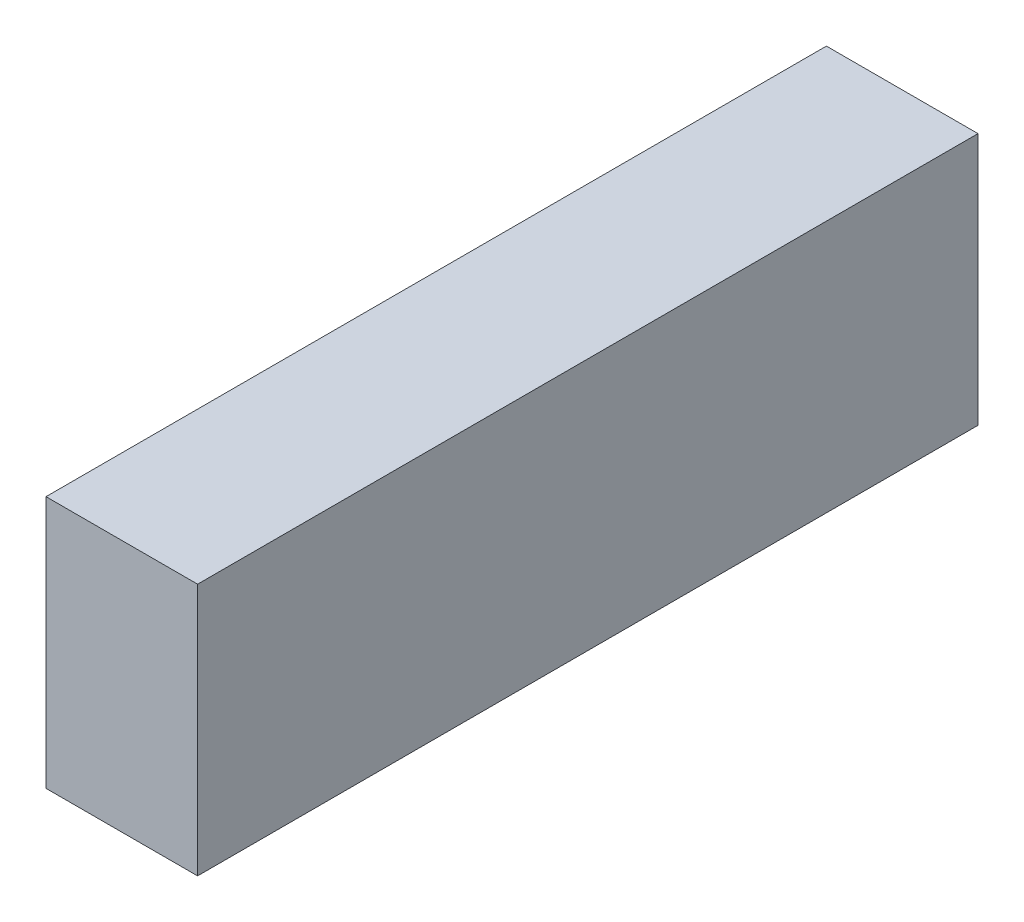
from build123d import *

# Parameters (mm, degrees)
SKETCH1_W           = 27
SKETCH1_H           = 45
BOSS_EXTRUDE1_DEPTH = 69.5


with BuildPart() as part:
    # Sketch1 → Boss-Extrude1 (new body, symmetric)
    with BuildSketch(Plane.XY):
        Rectangle(SKETCH1_W, SKETCH1_H)
    extrude(amount=BOSS_EXTRUDE1_DEPTH, both=True)


solid = part.part
